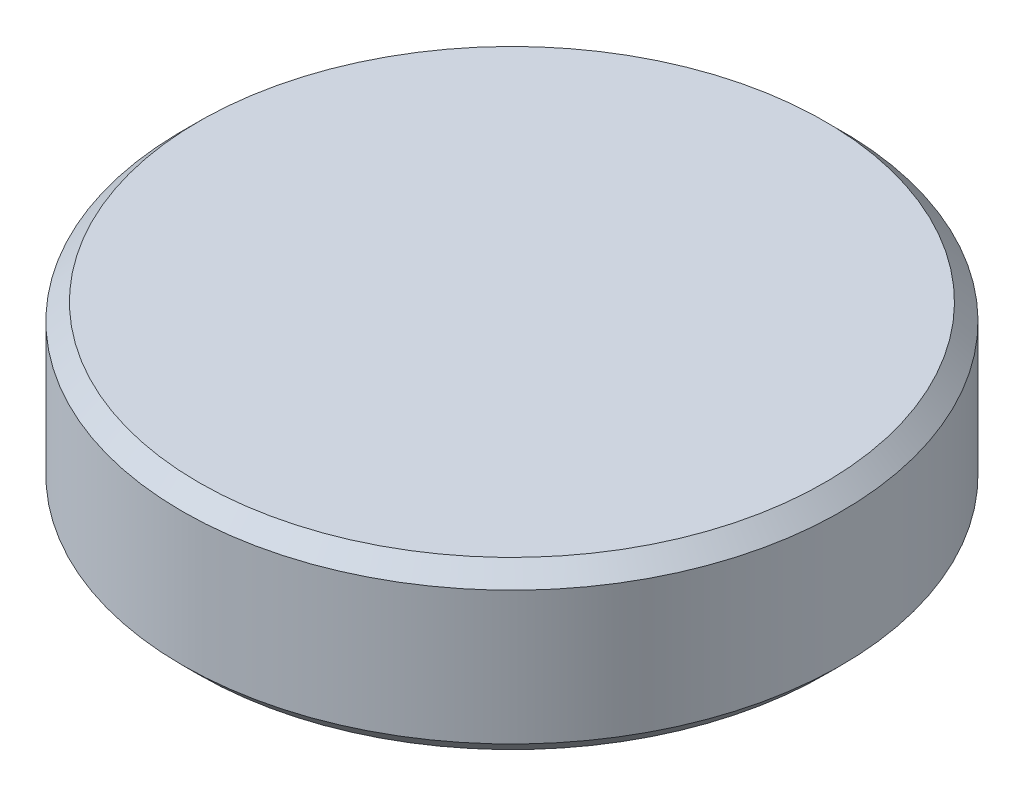
from build123d import *

# Parameters (mm, degrees)
SKETCH1_R           = 4.95
BOSS_EXTRUDE1_DEPTH = 2.5
CHAMFER1_SIZE       = 0.25


with BuildPart() as part:
    # Sketch1 → Boss-Extrude1 (new body)
    with BuildSketch(Plane(origin=(0, 0, 0), x_dir=(1, 0, 0), z_dir=(0, 1, 0))):
        Circle(SKETCH1_R)
    extrude(amount=BOSS_EXTRUDE1_DEPTH)

    # Chamfer1
    chamfer1_edges = [part.edges().sort_by_distance(p)[0] for p in [
        (-4.95, 0, 0),
        (-4.95, 2.5, 0),
    ]]
    chamfer(chamfer1_edges, length=CHAMFER1_SIZE)


solid = part.part
